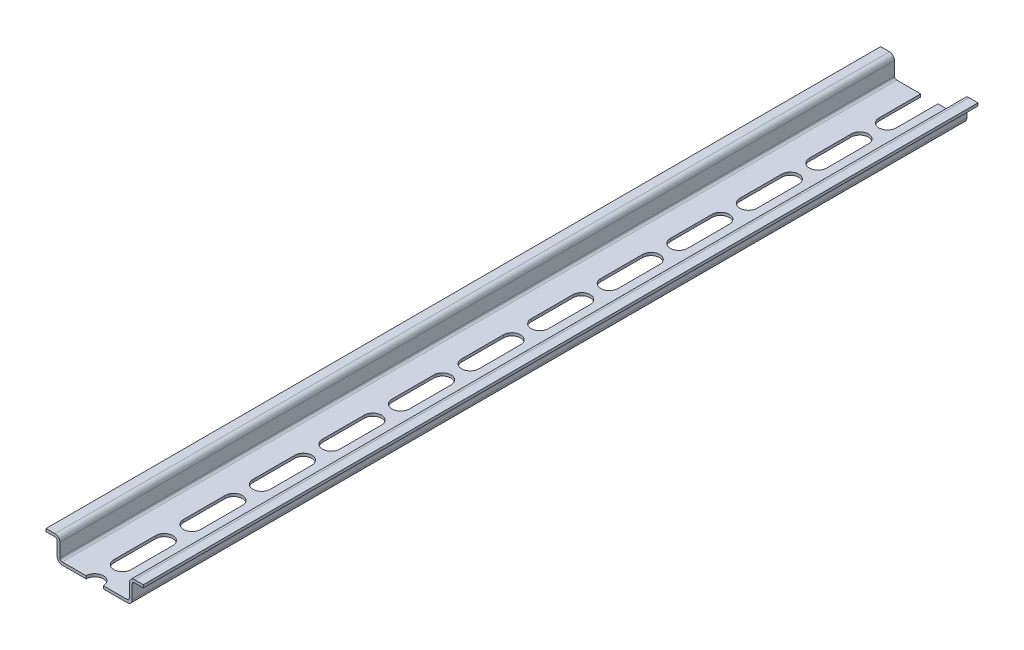
from build123d import *

# Parameters (mm, degrees)
BOSS_EXTRUDE2_DEPTH = 300
CUT_EXTRUDE1_DEPTH  = 100


with BuildPart() as part:
    # Sketch1 → Boss-Extrude2 (new body)
    with BuildSketch(Plane.XY):
        with BuildLine():
            Line((0, 0), (-11.7, 0))
            ThreePointArc((-11.7, 0), (-12.972792206, 0.527207794), (-13.5, 1.8))
            Line((-13.5, 1.8), (-13.5, 6.7))
            ThreePointArc((-13.5, 6.7), (-13.734314575, 7.265685425), (-14.3, 7.5))
            Line((-14.3, 7.5), (-17.5, 7.5))
            Line((-17.5, 7.5), (-17.5, 8.5))
            Line((-17.5, 8.5), (-14.3, 8.5))
            ThreePointArc((-14.3, 8.5), (-13.027207794, 7.972792206), (-12.5, 6.7))
            Line((-12.5, 6.7), (-12.5, 1.8))
            ThreePointArc((-12.5, 1.8), (-12.265685425, 1.234314575), (-11.7, 1))
            Line((-11.7, 1), (0, 1))
            Line((0, 1), (11.7, 1))
            ThreePointArc((11.7, 1), (12.265685425, 1.234314575), (12.5, 1.8))
            Line((12.5, 1.8), (12.5, 6.7))
            ThreePointArc((12.5, 6.7), (13.027207794, 7.972792206), (14.3, 8.5))
            Line((14.3, 8.5), (17.5, 8.5))
            Line((17.5, 8.5), (17.5, 7.5))
            Line((17.5, 7.5), (14.3, 7.5))
            ThreePointArc((14.3, 7.5), (13.734314575, 7.265685425), (13.5, 6.7))
            Line((13.5, 6.7), (13.5, 1.8))
            ThreePointArc((13.5, 1.8), (12.972792206, 0.527207794), (11.7, 0))
            Line((11.7, 0), (0, 0))
        make_face()
    extrude(amount=BOSS_EXTRUDE2_DEPTH)

    # Sketch2 → Cut-Extrude1 (cut)
    with BuildSketch(Plane(origin=(0, 1, 0), x_dir=(1, 0, 0), z_dir=(0, 1, 0))):
        with BuildLine():
            Line((-3.1, -290), (-3.1, -275))
            ThreePointArc((-3.1, -275), (0, -271.9), (3.1, -275))
            Line((3.1, -275), (3.1, -290))
            ThreePointArc((3.1, -290), (0, -293.1), (-3.1, -290))
        make_face()
        with BuildLine():
            Line((-3.1, -265), (-3.1, -250))
            ThreePointArc((-3.1, -250), (0, -246.9), (3.1, -250))
            Line((3.1, -250), (3.1, -265))
            ThreePointArc((3.1, -265), (0, -268.1), (-3.1, -265))
        make_face()
        with BuildLine():
            Line((-3.1, -240), (-3.1, -225))
            ThreePointArc((-3.1, -225), (0, -221.9), (3.1, -225))
            Line((3.1, -225), (3.1, -240))
            ThreePointArc((3.1, -240), (0, -243.1), (-3.1, -240))
        make_face()
        with BuildLine():
            Line((-3.1, -215), (-3.1, -200))
            ThreePointArc((-3.1, -200), (0, -196.9), (3.1, -200))
            Line((3.1, -200), (3.1, -215))
            ThreePointArc((3.1, -215), (0, -218.1), (-3.1, -215))
        make_face()
        with BuildLine():
            Line((-3.1, -315), (-3.1, -300))
            ThreePointArc((-3.1, -300), (0, -296.9), (3.1, -300))
            Line((3.1, -300), (3.1, -315))
            ThreePointArc((3.1, -315), (0, -318.1), (-3.1, -315))
        make_face()
        with BuildLine():
            Line((-3.1, -190), (-3.1, -175))
            ThreePointArc((-3.1, -175), (0, -171.9), (3.1, -175))
            Line((3.1, -175), (3.1, -190))
            ThreePointArc((3.1, -190), (0, -193.1), (-3.1, -190))
        make_face()
        with BuildLine():
            Line((-3.1, -165), (-3.1, -150))
            ThreePointArc((-3.1, -150), (0, -146.9), (3.1, -150))
            Line((3.1, -150), (3.1, -165))
            ThreePointArc((3.1, -165), (0, -168.1), (-3.1, -165))
        make_face()
        with BuildLine():
            Line((-3.1, -140), (-3.1, -125))
            ThreePointArc((-3.1, -125), (0, -121.9), (3.1, -125))
            Line((3.1, -125), (3.1, -140))
            ThreePointArc((3.1, -140), (0, -143.1), (-3.1, -140))
        make_face()
        with BuildLine():
            Line((-3.1, -115), (-3.1, -100))
            ThreePointArc((-3.1, -100), (0, -96.9), (3.1, -100))
            Line((3.1, -100), (3.1, -115))
            ThreePointArc((3.1, -115), (0, -118.1), (-3.1, -115))
        make_face()
        with BuildLine():
            Line((-3.1, -90), (-3.1, -75))
            ThreePointArc((-3.1, -75), (0, -71.9), (3.1, -75))
            Line((3.1, -75), (3.1, -90))
            ThreePointArc((3.1, -90), (0, -93.1), (-3.1, -90))
        make_face()
        with BuildLine():
            Line((-3.1, -65), (-3.1, -50))
            ThreePointArc((-3.1, -50), (0, -46.9), (3.1, -50))
            Line((3.1, -50), (3.1, -65))
            ThreePointArc((3.1, -65), (0, -68.1), (-3.1, -65))
        make_face()
        with BuildLine():
            Line((-3.1, -40), (-3.1, -25))
            ThreePointArc((-3.1, -25), (0, -21.9), (3.1, -25))
            Line((3.1, -25), (3.1, -40))
            ThreePointArc((3.1, -40), (0, -43.1), (-3.1, -40))
        make_face()
        with BuildLine():
            Line((-3.1, -15), (-3.1, 0))
            ThreePointArc((-3.1, 0), (0, 3.1), (3.1, 0))
            Line((3.1, 0), (3.1, -15))
            ThreePointArc((3.1, -15), (0, -18.1), (-3.1, -15))
        make_face()
    extrude(amount=-CUT_EXTRUDE1_DEPTH, mode=Mode.SUBTRACT)


solid = part.part
